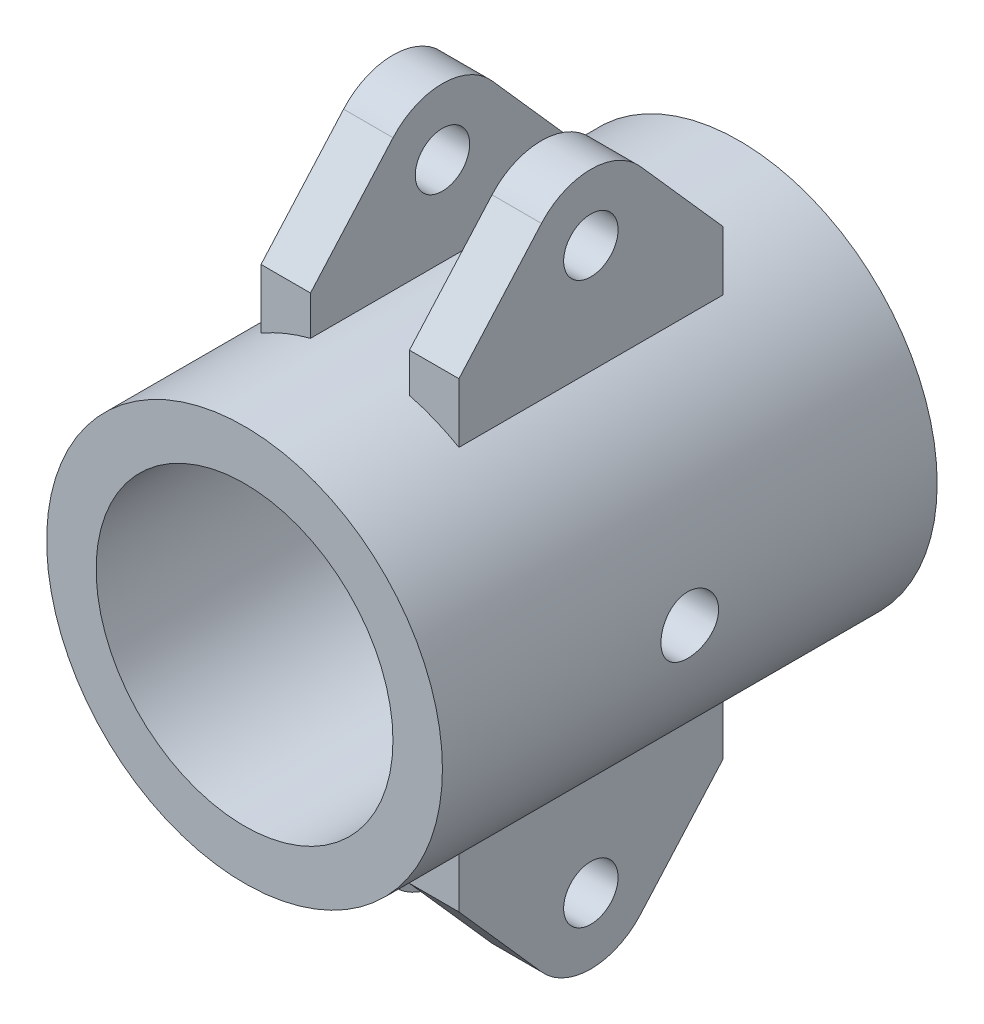
from build123d import *

# Parameters (mm, degrees)
SKETCH_1_R               = 12
SKETCH_1_R_2             = 9
EXTRUDE_1_DEPTH          = 30
SKETCH_2_R               = 1.65
EXTRUDE_2_DEPTH          = 3
SKETCH_3_R               = 1.75
CUT_EXTRUDE_1_DEPTH      = 13
CUT_EXTRUDE_1_DEPTH_BACK = 13
MIRROR_2_COPY_1_SKETCH_R = 1.65
MIRROR_2_COPY_1_DEPTH    = 3


with BuildPart() as part:
    # ｽｹｯﾁ1 → ﾎﾞｽ - 押し出し1 (new body)
    with BuildSketch(Plane.XY):
        Circle(SKETCH_1_R)
        Circle(SKETCH_1_R_2, mode=Mode.SUBTRACT)
    extrude(amount=EXTRUDE_1_DEPTH)

    # ｽｹｯﾁ2 → ﾎﾞｽ - 押し出し2 (add)
    with BuildSketch(Plane(origin=(3, 0, 0), x_dir=(0, 0, -1), z_dir=(1, 0, 0))):
        with BuildLine():
            Line((-23, 9), (-23, 14))
            Line((-23, 14), (-17.994493332, 19.651982218))
            ThreePointArc((-17.994493332, 19.651982218), (-15, 21), (-12.005506668, 19.651982218))
            Line((-12.005506668, 19.651982218), (-7, 14))
            Line((-7, 14), (-7, 9))
            Line((-7, 9), (-23, 9))
        make_face()
        with Locations((-15, 17)):
            Circle(SKETCH_2_R, mode=Mode.SUBTRACT)
    extrude_2 = extrude(amount=EXTRUDE_2_DEPTH)

    # ﾐﾗｰ1: ﾎﾞｽ - 押し出し2 across plane
    add(extrude_2.mirror(Plane(origin=(0, 0, 0), x_dir=(0, 0, 1), z_dir=(1, 0, 0))))

    # ｽｹｯﾁ3 → ｶｯﾄ - 押し出し1 (cut, two sides)
    with BuildSketch(Plane(origin=(0, 0, 0), x_dir=(0, 0, -1), z_dir=(1, 0, 0))) as cut_extrude_1_sk:
        with Locations((-15, 0)):
            Circle(SKETCH_3_R)
    extrude(amount=CUT_EXTRUDE_1_DEPTH, mode=Mode.SUBTRACT)
    extrude(cut_extrude_1_sk.sketch, amount=-CUT_EXTRUDE_1_DEPTH_BACK, mode=Mode.SUBTRACT)

    # ﾐﾗｰ2: ﾎﾞｽ - 押し出し2 across plane
    add(extrude_2.mirror(Plane.ZX))

    # ﾐﾗｰ2 copy 1 sketch → ﾐﾗｰ2 copy 1 (add)
    with BuildSketch(Plane(origin=(-3, 0, 0), x_dir=(0, 0, -1), z_dir=(-1, 0, 0))):
        with BuildLine():
            Line((-23, 9), (-23, 14))
            Line((-23, 14), (-17.994493332, 19.651982218))
            ThreePointArc((-17.994493332, 19.651982218), (-15, 21), (-12.005506668, 19.651982218))
            Line((-12.005506668, 19.651982218), (-7, 14))
            Line((-7, 14), (-7, 9))
            Line((-7, 9), (-23, 9))
        make_face()
        with Locations((-15, 17)):
            Circle(MIRROR_2_COPY_1_SKETCH_R, mode=Mode.SUBTRACT)
    extrude(amount=MIRROR_2_COPY_1_DEPTH)


solid = part.part
